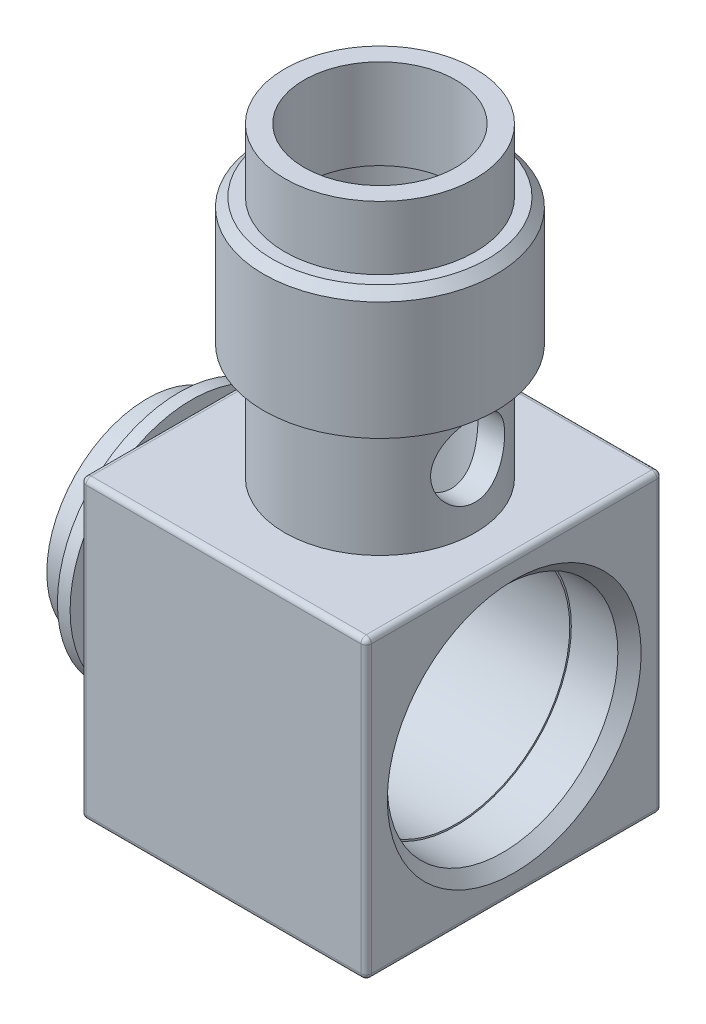
from build123d import *

# Parameters (mm, degrees)
SKETCH_2_R           = 9
EXTRUDE_1_DEPTH      = 25
SKETCH_3_R           = 11
EXTRUDE_2_DEPTH      = 12
SKETCH_4_R           = 9
EXTRUDE_3_DEPTH      = 6
SKETCH_5_R           = 10.75
CUT_EXTRUDE_1_DEPTH  = 23.1
CUT_EXTRUDE_START    = -8.5
SKETCH_6_R           = 8.5
CUT_EXTRUDE_2_DEPTH  = 7
CUT_EXTRUDE_3_REACH  = 43.5
SKETCH_8_R           = 6.75
SKETCH_9_R           = 3.5
CUT_EXTRUDE_4_DEPTH  = 35.7000001
SKETCH_10_R          = 10.75
EXTRUDE_4_DEPTH      = 5.95
CHAMFER_1_SIZE       = 0.828
SKETCH_12_W          = 28
SKETCH_12_H          = 28
SKETCH_12_R          = 13
EXTRUDE_5_DEPTH      = 27
CUT_EXTRUDE_5_REACH  = 30
SKETCH_13_R          = 6.75
CUT_EXTRUDE_6_REACH  = 59
SKETCH_14_R          = 7.172
SKETCH_16_R          = 10.8985
CUT_EXTRUDE_7_DEPTH  = 5.5
CHAMFER_3_SIZE       = 1.1015
CUT_EXTRUDE_11_REACH = 7.95
SKETCH_18_R          = 10.75
FILLET_1_R           = 0.5


with BuildPart() as part:
    # Эскиз1 → Повернуть1 (revolve)
    with BuildSketch(Plane.XY):
        Polygon((0, -7), (11.6, -7), (11.6, 0), (34.7, 0), (34.7, -10.5), (34.7, -14), (7.7, -14), (7.7, -9.5), (4.2, -9.5), (4.2, -11.5), (3, -11.5), (3, -9.5), (0, -9.5), align=None)
    revolve(axis=Axis((0, 0, 0), (1, 0, 0)))

    # Эскиз2 → Бобышка-Вытянуть1 (add)
    with BuildSketch(Plane(origin=(0, 0, 0), x_dir=(1, 0, 0), z_dir=(0, 1, 0))):
        with Locations((22, 0)):
            Circle(SKETCH_2_R)
    extrude(amount=EXTRUDE_1_DEPTH)

    # Эскиз3 → Бобышка-Вытянуть2 (add)
    with BuildSketch(Plane(origin=(0, 25, 0), x_dir=(1, 0, 0), z_dir=(0, 1, 0))):
        with Locations((22, 0)):
            Circle(SKETCH_3_R)
    extrude(amount=EXTRUDE_2_DEPTH)

    # Эскиз4 → Бобышка-Вытянуть3 (add)
    with BuildSketch(Plane(origin=(0, 37, 0), x_dir=(1, 0, 0), z_dir=(0, 1, 0))):
        with Locations((22, 0)):
            Circle(SKETCH_4_R)
    extrude(amount=EXTRUDE_3_DEPTH)

    # Эскиз5 → Вырез-Вытянуть1 (cut)
    with BuildSketch(Plane(origin=(34.7, 0, 0), x_dir=(0, 0, -1), z_dir=(1, 0, 0))):
        Circle(SKETCH_5_R)
    extrude(amount=-CUT_EXTRUDE_1_DEPTH, mode=Mode.SUBTRACT)

    # Эскиз6 → Вырез-Вытянуть2 (cut)
    with BuildSketch(Plane(origin=(0, 43, 0), x_dir=(1, 0, 0), z_dir=(0, 1, 0)).offset(CUT_EXTRUDE_START)):
        with Locations((22, 0)):
            Circle(SKETCH_6_R)
    extrude(amount=-CUT_EXTRUDE_2_DEPTH, mode=Mode.SUBTRACT)

    # Эскиз8 → Вырез-Вытянуть3 (cut, up to next)
    with BuildSketch(Plane(origin=(0, 27.5, 0), x_dir=(1, 0, 0), z_dir=(0, 1, 0)), mode=Mode.PRIVATE) as cut_extrude_3_sk1:
        with Locations((22, 0)):
            Circle(SKETCH_8_R)
    cut_extrude_3_tool1 = extrude(cut_extrude_3_sk1.sketch, amount=-CUT_EXTRUDE_3_REACH, mode=Mode.PRIVATE) & part.part
    add(cut_extrude_3_tool1.solids().sort_by_distance((22, 27.5, 0))[0], mode=Mode.SUBTRACT)

    # Эскиз9 → Вырез-Вытянуть4 (cut, through all)
    with BuildSketch(Plane(origin=(0, 0, 0), x_dir=(0, 0, -1), z_dir=(1, 0, 0))):
        with Locations((0, 20)):
            Circle(SKETCH_9_R)
    extrude(amount=CUT_EXTRUDE_4_DEPTH, mode=Mode.SUBTRACT)

    # Эскиз10 → Бобышка-Вытянуть4 (add)
    with BuildSketch(Plane(origin=(34.7, 0, 0), x_dir=(0, 0, -1), z_dir=(1, 0, 0))):
        Circle(SKETCH_10_R)
    extrude(amount=-EXTRUDE_4_DEPTH)

    # Фаска1
    chamfer_1_edges = [part.edges().sort_by_distance(p)[0] for p in [
        (11, 37, 0),
    ]]
    chamfer(chamfer_1_edges, length=CHAMFER_1_SIZE)

    # Эскиз12 → Бобышка-Вытянуть5 (add)
    with BuildSketch(Plane(origin=(34.7, 0, 0), x_dir=(0, 0, -1), z_dir=(1, 0, 0))):
        Rectangle(SKETCH_12_W, SKETCH_12_H)
        Circle(SKETCH_12_R, mode=Mode.SUBTRACT)
    extrude(amount=-EXTRUDE_5_DEPTH)

    # Эскиз13 → Вырез-Вытянуть5 (cut, up to next)
    with BuildSketch(Plane(origin=(0, 14, 0), x_dir=(1, 0, 0), z_dir=(0, 1, 0)), mode=Mode.PRIVATE) as cut_extrude_5_sk1:
        with Locations((22, 0)):
            Circle(SKETCH_13_R)
    cut_extrude_5_tool1 = extrude(cut_extrude_5_sk1.sketch, amount=-CUT_EXTRUDE_5_REACH, mode=Mode.PRIVATE) & part.part
    add(cut_extrude_5_tool1.solids().sort_by_distance((22, 14, 0))[0], mode=Mode.SUBTRACT)

    # Эскиз14 → Вырез-Вытянуть6 (cut, up to next)
    with BuildSketch(Plane(origin=(0, 43, 0), x_dir=(1, 0, 0), z_dir=(0, 1, 0)), mode=Mode.PRIVATE) as cut_extrude_6_sk1:
        with Locations((22, 0)):
            Circle(SKETCH_14_R)
    cut_extrude_6_tool1 = extrude(cut_extrude_6_sk1.sketch, amount=-CUT_EXTRUDE_6_REACH, mode=Mode.PRIVATE) & part.part
    add(cut_extrude_6_tool1.solids().sort_by_distance((22, 43, 0))[0], mode=Mode.SUBTRACT)

    # Эскиз16 → Вырез-Вытянуть7 (cut)
    with BuildSketch(Plane(origin=(34.7, 0, 0), x_dir=(0, 0, -1), z_dir=(1, 0, 0))):
        Circle(SKETCH_16_R)
    extrude(amount=-CUT_EXTRUDE_7_DEPTH, mode=Mode.SUBTRACT)

    # Фаска3
    chamfer_3_edges = [part.edges().sort_by_distance(p)[0] for p in [
        (34.7, 0, 10.8985),
    ]]
    chamfer(chamfer_3_edges, length=CHAMFER_3_SIZE)

    # Эскиз18 → Вырез-Вытянуть11 (cut, up to next)
    with BuildSketch(Plane.ZY.offset(-28.75), mode=Mode.PRIVATE) as cut_extrude_11_sk1:
        Circle(SKETCH_18_R)
    cut_extrude_11_tool1 = extrude(cut_extrude_11_sk1.sketch, amount=-CUT_EXTRUDE_11_REACH, mode=Mode.PRIVATE) & part.part
    add(cut_extrude_11_tool1.solids().sort_by_distance((28.75, 0, 0))[0], mode=Mode.SUBTRACT)

    # Скругление1
    fillet_1_edges = [part.edges().sort_by_distance(p)[0] for p in [
        (34.7, 0, 14),
        (34.7, -14, 0),
        (34.7, 0, -14),
        (34.7, 14, 0),
        (7.7, 0, -14),
        (21.2, 14, -14),
        (7.7, -14, 0),
        (21.2, -14, -14),
        (7.7, 0, 14),
        (21.2, -14, 14),
        (7.7, 14, 0),
        (21.2, 14, 14),
    ]]
    fillet(fillet_1_edges, radius=FILLET_1_R)


solid = part.part
